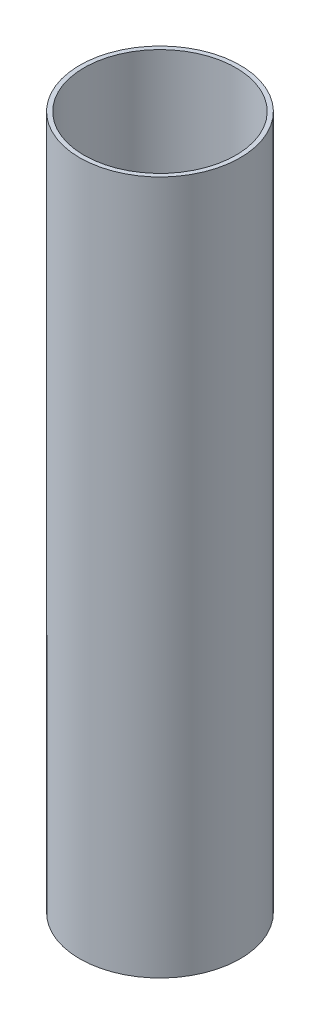
from build123d import *

# Parameters (mm, degrees)
SKETCH2_R           = 58.7375
SKETCH2_R_2         = 55.5625
BOSS_EXTRUDE1_DEPTH = 508


with BuildPart() as part:
    # Sketch2 → Boss-Extrude1 (new body)
    with BuildSketch(Plane(origin=(0, 0, 0), x_dir=(1, 0, 0), z_dir=(0, 1, 0))):
        Circle(SKETCH2_R)
        Circle(SKETCH2_R_2, mode=Mode.SUBTRACT)
    extrude(amount=BOSS_EXTRUDE1_DEPTH)


solid = part.part
